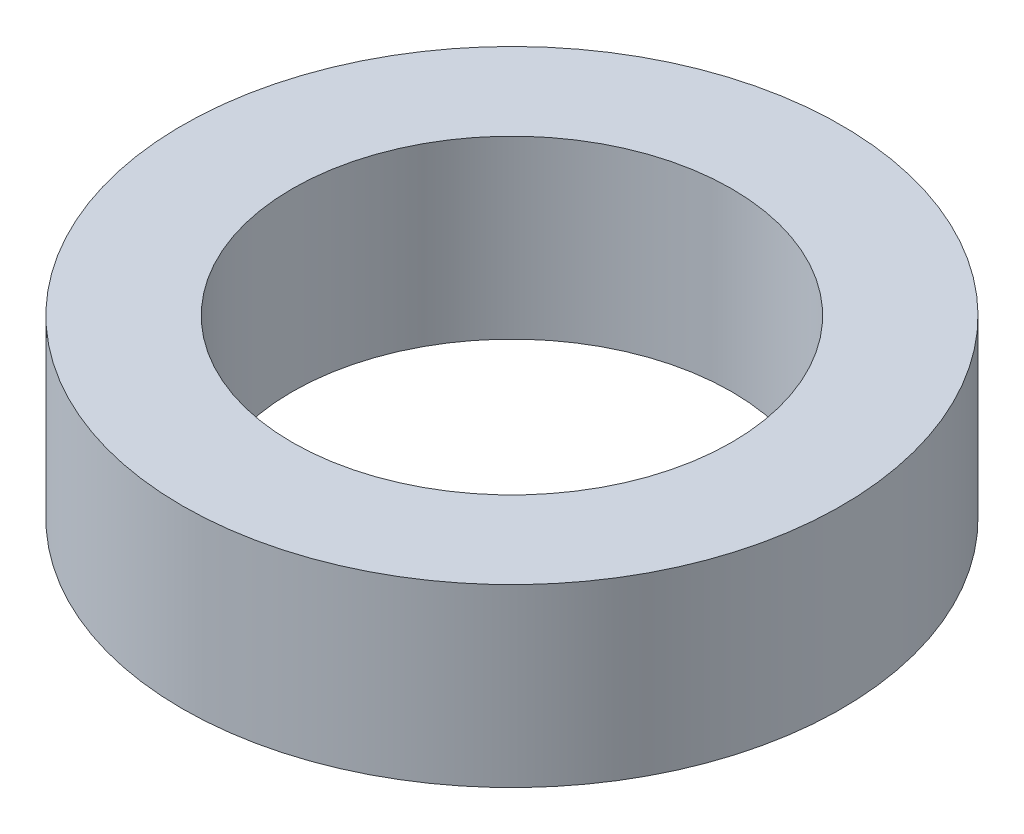
from build123d import *

# Parameters (mm, degrees)
SKETCH1_R           = 7.5
SKETCH1_R_2         = 5
BOSS_EXTRUDE1_DEPTH = 4


with BuildPart() as part:
    # Sketch1 → Boss-Extrude1 (new body)
    with BuildSketch(Plane(origin=(0, 0, 0), x_dir=(1, 0, 0), z_dir=(0, 1, 0))):
        Circle(SKETCH1_R)
        Circle(SKETCH1_R_2, mode=Mode.SUBTRACT)
    extrude(amount=BOSS_EXTRUDE1_DEPTH)


solid = part.part
